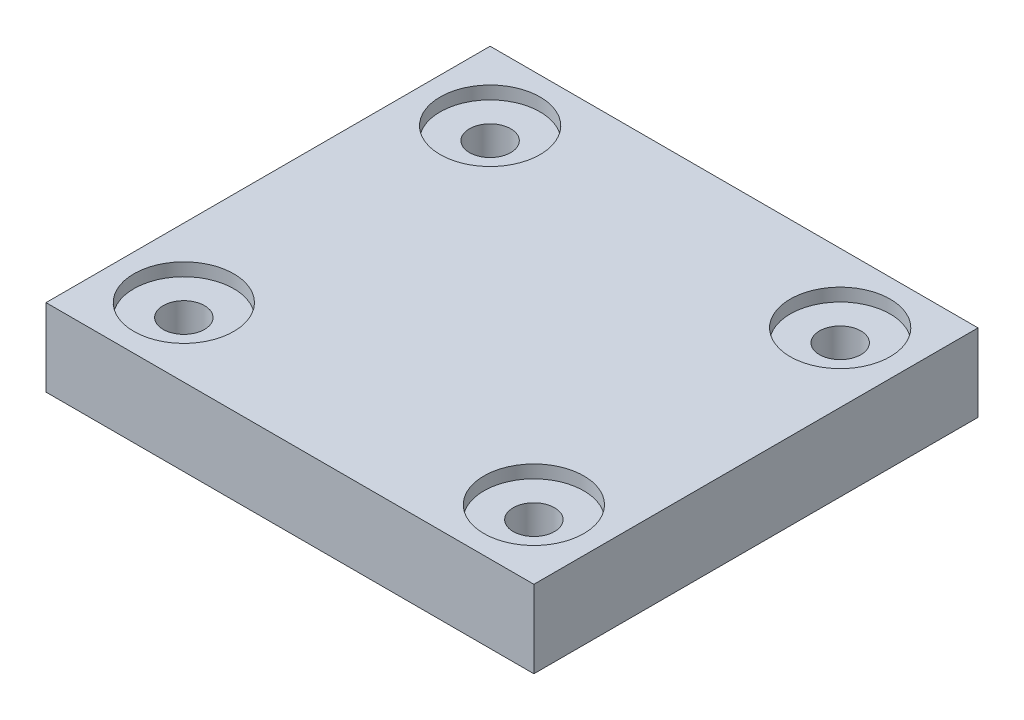
from build123d import *

# Parameters (mm, degrees)
SKETCH1_W           = 28.32
SKETCH1_H           = 25.78
SKETCH1_R           = 1.2
BOSS_EXTRUDE1_DEPTH = 5
SKETCH3_R           = 2.9
CUT_EXTRUDE1_DEPTH  = 0.75
CHAMFER1_SIZE       = 0.5


with BuildPart() as part:
    # Sketch1 → Boss-Extrude1 (new body)
    with BuildSketch(Plane(origin=(0, 0, 0), x_dir=(1, 0, 0), z_dir=(0, 1, 0))):
        Rectangle(SKETCH1_W, SKETCH1_H)
        with Locations((-10.16, 8.89)):
            Circle(SKETCH1_R, mode=Mode.SUBTRACT)
        with Locations((10.16, 8.89)):
            Circle(SKETCH1_R, mode=Mode.SUBTRACT)
        with Locations((10.16, -8.89)):
            Circle(SKETCH1_R, mode=Mode.SUBTRACT)
        with Locations((-10.16, -8.89)):
            Circle(SKETCH1_R, mode=Mode.SUBTRACT)
    extrude(amount=BOSS_EXTRUDE1_DEPTH)

    # Sketch3 → Cut-Extrude1 (cut)
    with BuildSketch(Plane(origin=(0, 5, 0), x_dir=(1, 0, 0), z_dir=(0, 1, 0))):
        with Locations((-10.16, 8.89)):
            Circle(SKETCH3_R)
        with Locations((10.16, 8.89)):
            Circle(SKETCH3_R)
        with Locations((10.16, -8.89)):
            Circle(SKETCH3_R)
        with Locations((-10.16, -8.89)):
            Circle(SKETCH3_R)
    extrude(amount=-CUT_EXTRUDE1_DEPTH, mode=Mode.SUBTRACT)

    # Chamfer1
    chamfer1_edges = [part.edges().sort_by_distance(p)[0] for p in [
        (-11.36, 0, -8.89),
        (8.96, 0, -8.89),
        (8.96, 0, 8.89),
        (-11.36, 0, 8.89),
        (-14.16, 0, 0),
        (0, 0, -12.89),
        (14.16, 0, 0),
        (0, 0, 12.89),
    ]]
    chamfer(chamfer1_edges, length=CHAMFER1_SIZE)


solid = part.part
